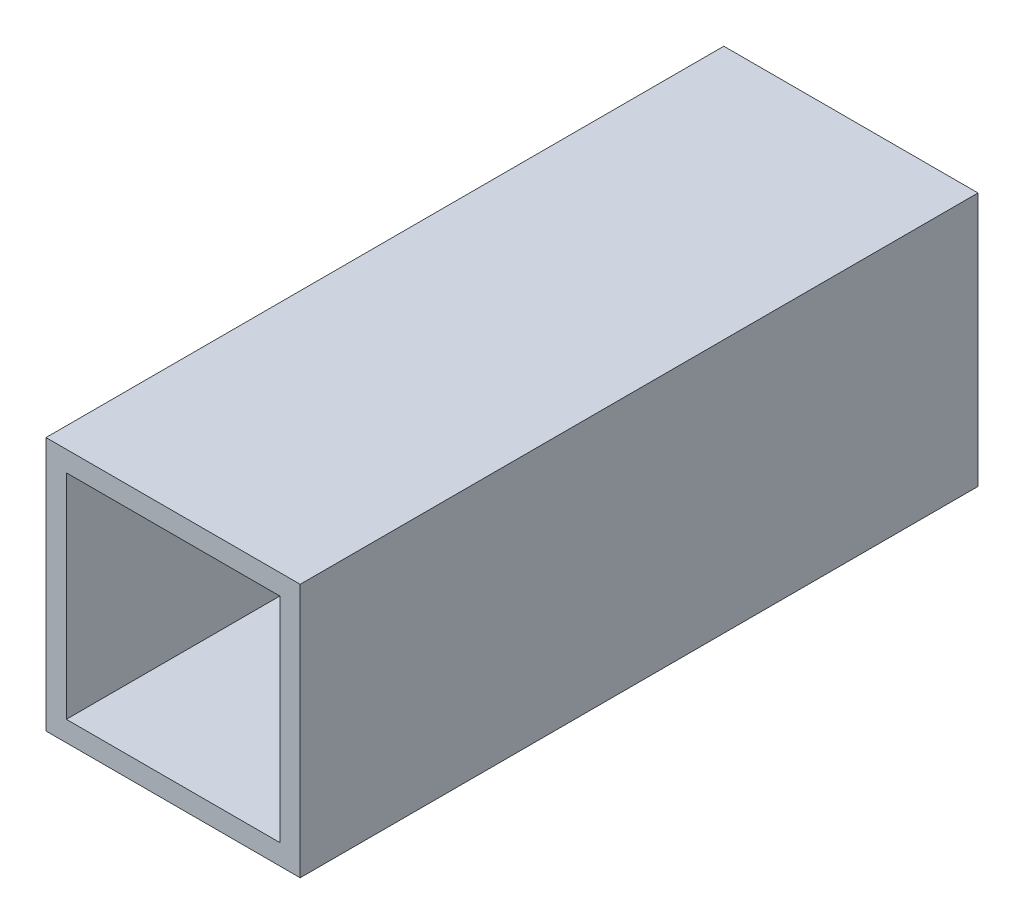
from build123d import *

# Parameters (mm, degrees)
SKETCH1_W           = 38.1
SKETCH1_H           = 38.1
SKETCH1_W_2         = 32.004
SKETCH1_H_2         = 32.004
BOSS_EXTRUDE1_DEPTH = 50.8


with BuildPart() as part:
    # Sketch1 → Boss-Extrude1 (new body, symmetric)
    with BuildSketch(Plane.XY):
        Rectangle(SKETCH1_W, SKETCH1_H)
        Rectangle(SKETCH1_W_2, SKETCH1_H_2, mode=Mode.SUBTRACT)
    extrude(amount=BOSS_EXTRUDE1_DEPTH, both=True)


solid = part.part
